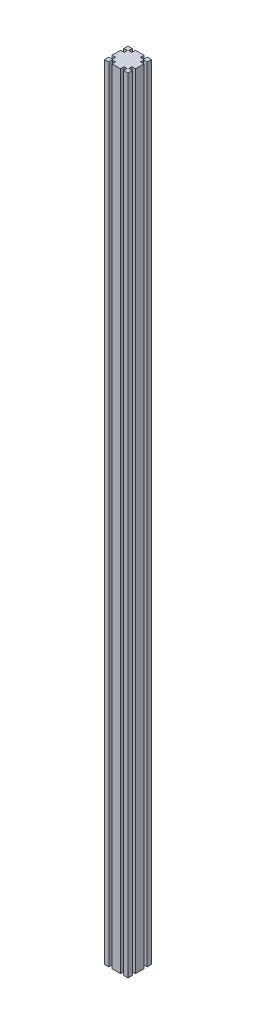
from build123d import *

# Parameters (mm, degrees)
EXTRUDE_1_DEPTH = 2000


with BuildPart() as part:
    # 草图1 → 凸台-拉伸1 (new body)
    with BuildSketch(Plane(origin=(0, 0, 0), x_dir=(1, 0, 0), z_dir=(0, 1, 0))):
        Polygon((10.9, 60), (0, 60), (0, 49.1), (9.2, 49.1), (9.2, 40.9), (0, 40.9), (0, 30), (30, 30), (30, 60), (19.1, 60), (19.1, 50.8), (10.9, 50.8), align=None)
        Polygon((40.9, 60), (30, 60), (30, 30), (60, 30), (60, 40.9), (50.8, 40.9), (50.8, 49.1), (60, 49.1), (60, 60), (49.1, 60), (49.1, 50.8), (40.9, 50.8), align=None)
        Polygon((60, 30), (30, 30), (30, 0), (40.9, 0), (40.9, 9.2), (49.1, 9.2), (49.1, 0), (60, 0), (60, 10.9), (50.8, 10.9), (50.8, 19.1), (60, 19.1), align=None)
        Polygon((30, 30), (0, 30), (30, 0), align=None)
        Polygon((30, 0), (0, 30), (0, 19.1), (9.2, 19.1), (9.2, 10.9), (0, 10.9), (0, 0), (10.9, 0), (10.9, 9.2), (19.1, 9.2), (19.1, 0), align=None)
    extrude(amount=EXTRUDE_1_DEPTH)


solid = part.part
